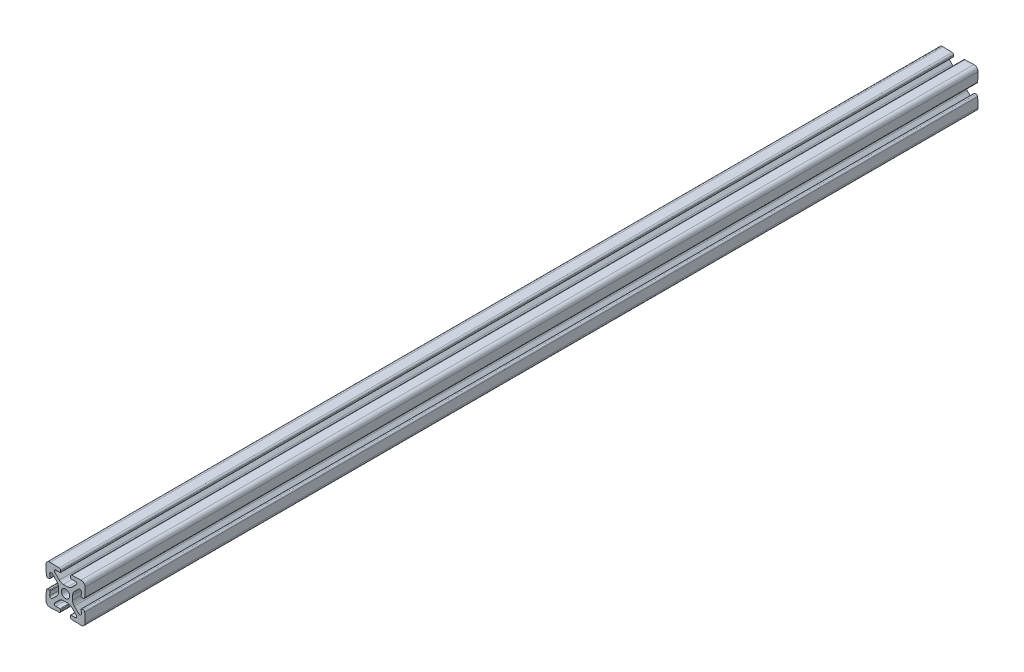
from build123d import *

# Parameters (mm, degrees)
BOSS_EXTRUDE1_DEPTH = 228.6
CIRPATTERN1_COUNT   = 4


with BuildPart() as part:
    # Sketch3 → Boss-Extrude1 (new body, symmetric)
    with BuildSketch(Plane.XY):
        with BuildLine():
            Line((-2.524916986, 8.30911066), (-2.500487338, 9.008684239))
            ThreePointArc((-2.500487338, 9.008684239), (-2.714917039, 9.582202525), (-3.272080403, 9.836116498))
            Line((-3.272080403, 9.836116498), (-7.930201007, 9.998781654))
            ThreePointArc((-7.930201007, 9.998781654), (-9.414213562, 9.414213562), (-9.998781654, 7.930201007))
            Line((-9.998781654, 7.930201007), (-9.836116498, 3.272080403))
            ThreePointArc((-9.836116498, 3.272080403), (-9.582202525, 2.714917039), (-9.008684239, 2.500487338))
            Line((-9.008684239, 2.500487338), (-8.30911066, 2.524916986))
            ThreePointArc((-8.30911066, 2.524916986), (-8.100174399, 2.620134726), (-8.019763261, 2.835204083))
            Line((-8.019763261, 2.835204083), (-8.093719461, 4.953032548))
            ThreePointArc((-8.093719461, 4.953032548), (-7.631170264, 5.686128657), (-6.779559917, 5.52444538))
            Line((-6.779559917, 5.52444538), (-4.478679656, 3.22356512))
            ThreePointArc((-4.478679656, 3.22356512), (-3.828361402, 2.250295073), (-3.6, 1.102244776))
            Line((-3.6, 1.102244776), (-3.6, 0))
            Line((-3.6, 0), (-2.15, 0))
            ThreePointArc((-2.15, 0), (-1.52027958, 1.52027958), (0, 2.15))
            Line((0, 2.15), (0, 3.6))
            Line((0, 3.6), (-1.102244776, 3.6))
            ThreePointArc((-1.102244776, 3.6), (-2.250295073, 3.828361402), (-3.22356512, 4.478679656))
            Line((-3.22356512, 4.478679656), (-5.52444538, 6.779559917))
            ThreePointArc((-5.52444538, 6.779559917), (-5.686128657, 7.631170264), (-4.953032548, 8.093719461))
            Line((-4.953032548, 8.093719461), (-2.835204083, 8.019763261))
            ThreePointArc((-2.835204083, 8.019763261), (-2.620134726, 8.100174399), (-2.524916986, 8.30911066))
        make_face()
    boss_extrude1 = extrude(amount=BOSS_EXTRUDE1_DEPTH, both=True)

    # CirPattern1: Boss-Extrude1 ×4 about axis
    cirpattern1_axis = Axis((0, 0, 0), (0, 0, 1))
    for i in range(1, CIRPATTERN1_COUNT):
        add(boss_extrude1.rotate(cirpattern1_axis, i * 360 / CIRPATTERN1_COUNT))


solid = part.part
